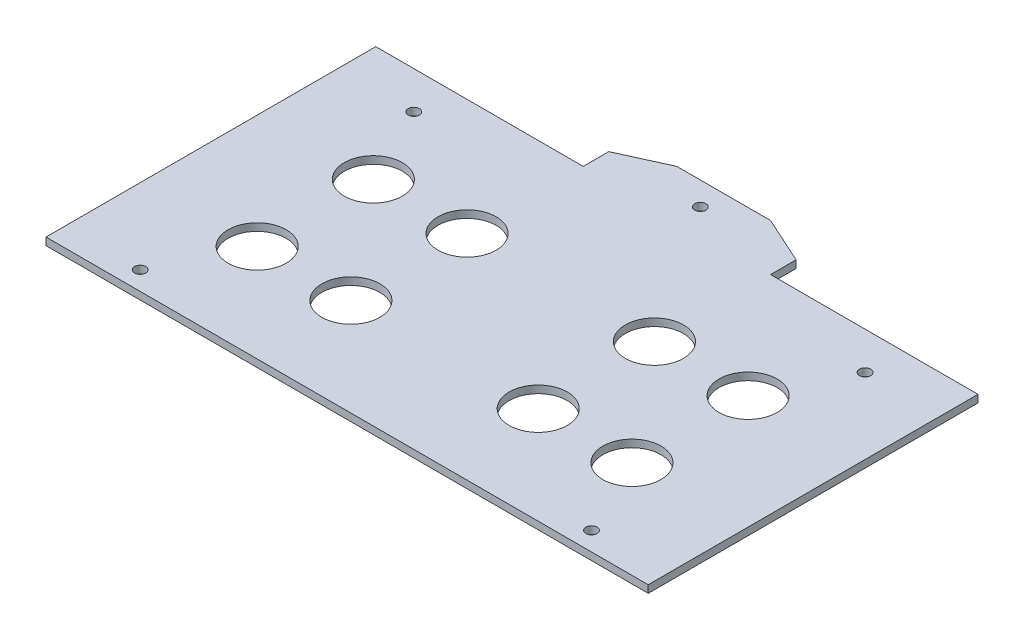
from build123d import *

# Parameters (mm, degrees)
SKETCH1_W           = 155.702807198
SKETCH1_H           = 58
SKETCH1_R           = 1.5
BOSS_EXTRUDE2_DEPTH = 2
SKETCH2_W           = 5
SKETCH2_H           = 88
BOSS_EXTRUDE3_DEPTH = 2
SKETCH3_R           = 7.75
CUT_EXTRUDE1_DEPTH  = 10
SKETCH4_R           = 1.5
BOSS_EXTRUDE4_DEPTH = 2
SKETCH7_W           = 2.5
SKETCH7_H           = 88
CUT_EXTRUDE2_DEPTH  = 10


with BuildPart() as part:
    # Sketch1 → Boss-Extrude2 (new body)
    with BuildSketch(Plane(origin=(0, 0, 0), x_dir=(1, 0, 0), z_dir=(0, 1, 0))):
        with Locations((1.171695753, -5)):
            Rectangle(SKETCH1_W, SKETCH1_H)
        Polygon((-76.679707846, 44), (-76.679707846, 24), (79.023099352, 24), (79.023099352, 44), (62.885457038, 44), (59.885457038, 44), (-57.542065533, 44), (-60.542065533, 44), align=None)
        with Locations((-59.042065533, 34)):
            Circle(SKETCH1_R, mode=Mode.SUBTRACT)
        with Locations((61.385457038, 34)):
            Circle(SKETCH1_R, mode=Mode.SUBTRACT)
        Polygon((-76.679707846, -44), (-60.542065533, -44), (-57.542065533, -44), (59.885457038, -44), (62.885457038, -44), (79.023099352, -44), (79.023099352, -34), (-76.679707846, -34), align=None)
        with Locations((-59.042065533, -39)):
            Circle(SKETCH1_R, mode=Mode.SUBTRACT)
        with Locations((61.385457038, -39)):
            Circle(SKETCH1_R, mode=Mode.SUBTRACT)
    extrude(amount=BOSS_EXTRUDE2_DEPTH)

    # Sketch2 → Boss-Extrude3 (add)
    with BuildSketch(Plane(origin=(0, 2, 0), x_dir=(1, 0, 0), z_dir=(0, 1, 0))):
        with Locations((81.523099352, 0)):
            Rectangle(SKETCH2_W, SKETCH2_H)
        with Locations((-79.179707846, 0)):
            Rectangle(SKETCH2_W, SKETCH2_H)
    extrude(amount=-BOSS_EXTRUDE3_DEPTH)

    # Sketch3 → Cut-Extrude1 (cut)
    with BuildSketch(Plane(origin=(0, 2, 0), x_dir=(1, 0, 0), z_dir=(0, 1, 0))):
        with Locations((26.171695753, 13)):
            Circle(SKETCH3_R)
        with Locations((51.171695753, 13)):
            Circle(SKETCH3_R)
        with Locations((-23.828304247, 13)):
            Circle(SKETCH3_R)
        with Locations((-48.828304247, 13)):
            Circle(SKETCH3_R)
        with Locations((-48.828304247, -18)):
            Circle(SKETCH3_R)
        with Locations((-23.828304247, -18)):
            Circle(SKETCH3_R)
        with Locations((51.171695753, -18)):
            Circle(SKETCH3_R)
        with Locations((26.171695753, -18)):
            Circle(SKETCH3_R)
    extrude(amount=-CUT_EXTRUDE1_DEPTH, mode=Mode.SUBTRACT)

    # Sketch4 → Boss-Extrude4 (add)
    with BuildSketch(Plane(origin=(0, 2, 0), x_dir=(1, 0, 0), z_dir=(0, 1, 0))):
        Polygon((-23.828304247, 44), (26.171695753, 44), (26.171695753, 50.823606938), (13.671695753, 56.49492606), (-11.328304247, 56.49492606), (-23.828304247, 50.823606938), align=None)
        with Locations((1.171695753, 50.24746303)):
            Circle(SKETCH4_R, mode=Mode.SUBTRACT)
    extrude(amount=-BOSS_EXTRUDE4_DEPTH)

    # Sketch7 → Cut-Extrude2 (cut)
    with BuildSketch(Plane(origin=(0, 2, 0), x_dir=(1, 0, 0), z_dir=(0, 1, 0))):
        with Locations((-80.429707846, 0)):
            Rectangle(SKETCH7_W, SKETCH7_H)
        with Locations((82.773099352, 0)):
            Rectangle(SKETCH7_W, SKETCH7_H)
    extrude(amount=-CUT_EXTRUDE2_DEPTH, mode=Mode.SUBTRACT)


solid = part.part
